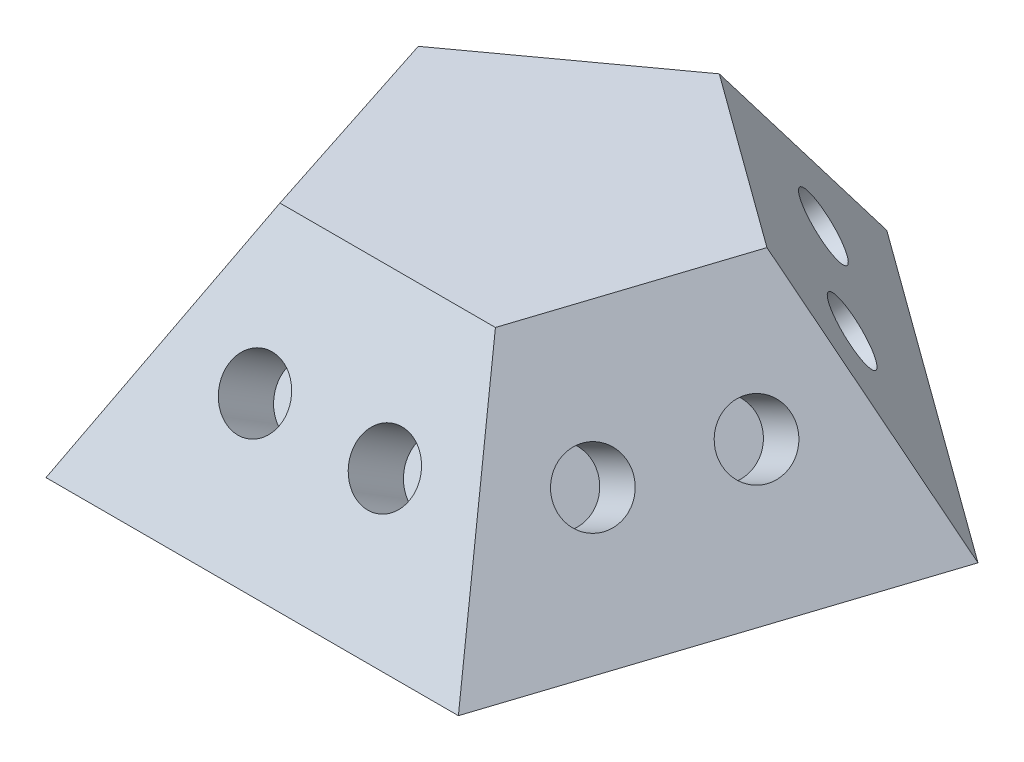
from build123d import *

# Parameters (mm, degrees)
BOSS_EXTRUDE1_DEPTH = 6.752040791
BOSS_EXTRUDE1_TAPER = 31.717474411
SKETCH3_R           = 1
CUT_EXTRUDE1_DEPTH  = 2
CIRPATTERN1_COUNT   = 5


with BuildPart() as part:
    # Sketch1 → Boss-Extrude1 (new body)
    with BuildSketch(Plane(origin=(0, 0, 0), x_dir=(1, 0, 0), z_dir=(0, 1, 0))):
        Polygon((0, 10.803265266), (-10.274515829, 3.338392562), (-6.35, -8.740025195), (6.35, -8.740025195), (10.274515829, 3.338392562), align=None)
    extrude(amount=BOSS_EXTRUDE1_DEPTH, taper=BOSS_EXTRUDE1_TAPER)

    # Sketch3 → Cut-Extrude1 (cut)
    with BuildSketch(Plane(origin=(0, 3.908658092, 6.324341644), x_dir=(1, 0, 0), z_dir=(1.6266940928737823e-15, 0.5257311121191348, 0.8506508083520392))):
        with Locations((-2, -0.626153166)):
            Circle(SKETCH3_R)
        with Locations((2, -0.626153166)):
            Circle(SKETCH3_R)
    cut_extrude1 = extrude(amount=-CUT_EXTRUDE1_DEPTH, mode=Mode.SUBTRACT)

    # CirPattern1: Cut-Extrude1 ×5 about axis
    cirpattern1_axis = Axis((0, 14.848740719, 0), (0, -1, 0))
    for i in range(1, CIRPATTERN1_COUNT):
        add(cut_extrude1.rotate(cirpattern1_axis, i * 360 / CIRPATTERN1_COUNT), mode=Mode.SUBTRACT)


solid = part.part
